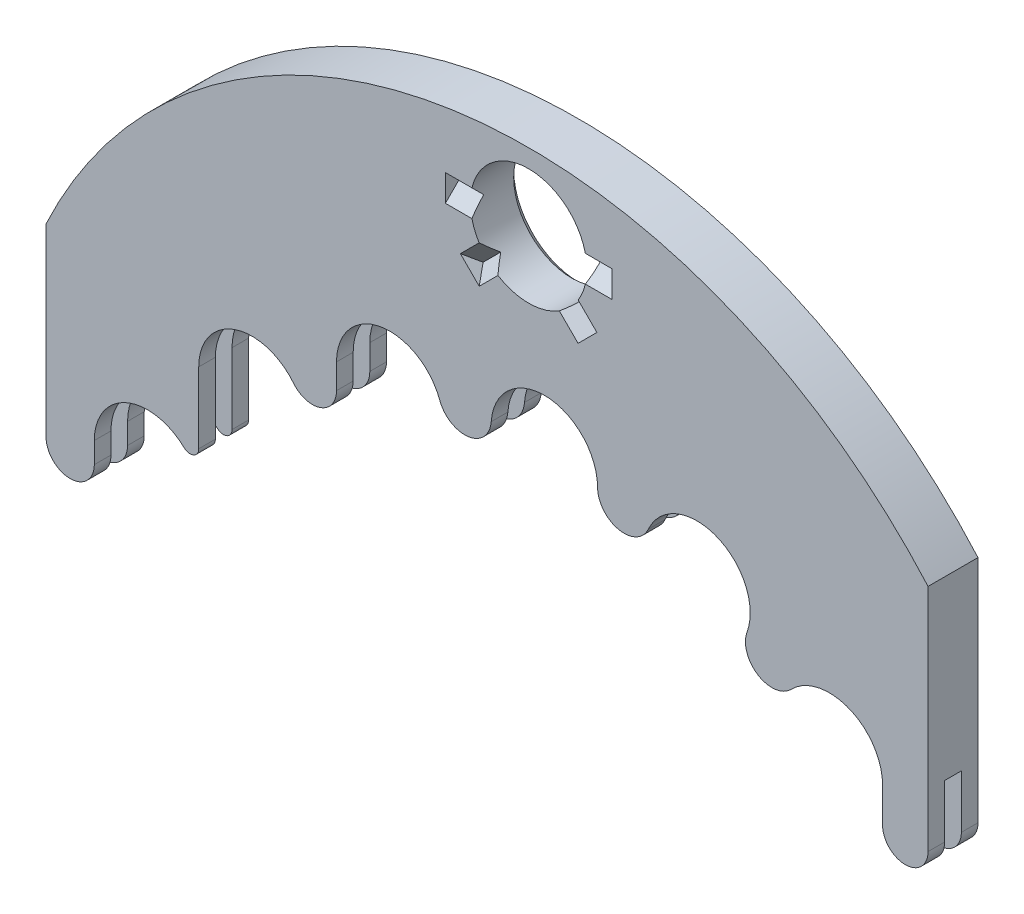
from build123d import *

# Parameters (mm, degrees)
SKETCH1_W               = 26.5
SKETCH1_H               = 15.5
BOSS_EXTRUDE1_DEPTH     = 0.75
CUT_EXTRUDE1_START      = -1.5
CUT_EXTRUDE1_DEPTH      = 1.5
SKETCH3_R               = 16
CUT_EXTRUDE2_DEPTH      = 0.25
SKETCH5_R               = 13
CUT_EXTRUDE3_DEPTH      = 2.5
CUT_EXTRUDE9_DEPTH      = 2.5
SKETCH8_R               = 1.75
CUT_EXTRUDE6_DEPTH      = 2.5
SKETCH4_R               = 1.6
CUT_EXTRUDE7_DEPTH      = 1.75
CUT_EXTRUDE7_DEPTH_BACK = 1.75
CUT_EXTRUDE8_DEPTH      = 2.5
CUT_EXTRUDE10_DEPTH     = 2.5
CUT_EXTRUDE11_DEPTH     = 2.5
CHAMFER1_SIZE           = 0.2
CUT_EXTRUDE12_DEPTH     = 2.5
CIRPATTERN1_COUNT       = 2
CIRPATTERN1_ANGLE       = 45
MIRROR1_COPY_1_DEPTH    = 2.5


with BuildPart() as part:
    # Sketch1 → Boss-Extrude1 (new body, symmetric)
    with BuildSketch(Plane.XY):
        Rectangle(SKETCH1_W, SKETCH1_H)
    extrude(amount=BOSS_EXTRUDE1_DEPTH, both=True)

    # Sketch2 → Cut-Extrude1 (cut)
    with BuildSketch(Plane.XY.offset(0.75).offset(CUT_EXTRUDE1_START)):
        with BuildLine():
            Line((-13.25, 9.75), (-13.25, -1.486125371))
            ThreePointArc((-13.25, -1.486125371), (-1.032310159, 7.586384068), (13.25, 2.333005244))
            Line((13.25, 2.333005244), (13.25, 9.75))
            Line((13.25, 9.75), (-13.25, 9.75))
        make_face()
    extrude(amount=CUT_EXTRUDE1_DEPTH, mode=Mode.SUBTRACT)

    # Sketch3 → Cut-Extrude2 (cut, symmetric)
    with BuildSketch(Plane.XY):
        with Locations((1.25, -13.55)):
            Circle(SKETCH3_R)
    extrude(amount=CUT_EXTRUDE2_DEPTH, both=True, mode=Mode.SUBTRACT)

    # Sketch5 → Cut-Extrude3 (cut, through all)
    with BuildSketch(Plane.XY.offset(0.75)):
        with Locations((1.25, -13.55)):
            Circle(SKETCH5_R)
    extrude(amount=-CUT_EXTRUDE3_DEPTH, mode=Mode.SUBTRACT)

    # Sketch11 → Cut-Extrude9 (cut, through all)
    with BuildSketch(Plane.XY.offset(0.75)):
        with BuildLine():
            Line((11.255498488, -5.25), (13.25, -5.25))
            Line((13.25, -5.25), (13.25, -7.75))
            Line((13.25, -7.75), (12.884431658, -7.75))
            ThreePointArc((12.884431658, -7.75), (12.141930232, -6.453109426), (11.255498488, -5.25))
        make_face()
    extrude(amount=-CUT_EXTRUDE9_DEPTH, mode=Mode.SUBTRACT)

    # Sketch8 → Cut-Extrude6 (cut, through all)
    with BuildSketch(Plane.XY.offset(0.75)):
        with Locations((1.25, 5.45)):
            Circle(SKETCH8_R)
    extrude(amount=-CUT_EXTRUDE6_DEPTH, mode=Mode.SUBTRACT)

    # Sketch4 → Cut-Extrude7 (cut, two sides)
    with BuildSketch(Plane.XY) as cut_extrude7_sk:
        with Locations((1.721143205, -0.058223835)):
            Circle(SKETCH4_R)
        with Locations((6.307189011, -1.033017963)):
            Circle(SKETCH4_R)
        with Locations((10.283263186, -3.517544856)):
            Circle(SKETCH4_R)
        with Locations((-2.921729424, -0.71073703)):
            Circle(SKETCH4_R)
        with Locations((-7.061429917, -2.911854826)):
            Circle(SKETCH4_R)
        with Locations((-10.198649298, -6.396089933)):
            Circle(SKETCH4_R)
    extrude(amount=CUT_EXTRUDE7_DEPTH, mode=Mode.SUBTRACT)
    extrude(cut_extrude7_sk.sketch, amount=-CUT_EXTRUDE7_DEPTH_BACK, mode=Mode.SUBTRACT)

    # Sketch9 → Cut-Extrude8 (cut, through all)
    with BuildSketch(Plane.XY.offset(0.75)):
        with BuildLine():
            Line((-11.798649298, -6.396089933), (-11.798649298, -7.024324649))
            ThreePointArc((-11.798649298, -7.024324649), (-12.524324649, -7.75), (-13.25, -7.024324649))
            Line((-13.25, -7.024324649), (-13.25, -8.25))
            Line((-13.25, -8.25), (-11.05124975, -8.25))
            Line((-11.05124975, -8.25), (-11.05124975, -7.75))
            ThreePointArc((-11.05124975, -7.75), (-11.599392087, -7.169342569), (-11.798649298, -6.396089933))
        make_face()
    extrude(amount=-CUT_EXTRUDE8_DEPTH, mode=Mode.SUBTRACT)

    # Sketch12 → Cut-Extrude10 (cut, through all)
    with BuildSketch(Plane.XY.offset(0.75)):
        with BuildLine():
            Line((11.883263186, -3.517544856), (11.883263186, -4.566631593))
            ThreePointArc((11.883263186, -4.566631593), (12.566631593, -5.25), (13.25, -4.566631593))
            Line((13.25, -4.566631593), (13.25, -5.75))
            Line((13.25, -5.75), (11.255498488, -5.75))
            Line((11.255498488, -5.75), (11.255498488, -5.25))
            ThreePointArc((11.255498488, -5.25), (11.12789237, -5.098536084), (10.997993608, -4.949033739))
            ThreePointArc((10.997993608, -4.949033739), (11.644066014, -4.359100358), (11.883263186, -3.517544856))
        make_face()
    extrude(amount=-CUT_EXTRUDE10_DEPTH, mode=Mode.SUBTRACT)

    # Sketch13 → Cut-Extrude11 (cut, through all)
    with BuildSketch(Plane.XY.offset(0.75)):
        with BuildLine():
            Line((-8.661429917, -2.911854826), (-8.661429917, -5.042786286))
            ThreePointArc((-8.661429917, -5.042786286), (-8.818746964, -5.281977988), (-9.100687262, -5.232268912))
            ThreePointArc((-9.100687262, -5.232268912), (-8.836495341, -5.556723149), (-8.665455555, -5.938578244))
            ThreePointArc((-8.665455555, -5.938578244), (1.881828141, -1.065978484), (11.883263186, -6.978568343))
            Line((11.883263186, -6.978568343), (11.883263186, -3.517544856))
            ThreePointArc((11.883263186, -3.517544856), (10.883946092, -2.034581591), (9.134288128, -2.404056501))
            ThreePointArc((9.134288128, -2.404056501), (8.138950435, -2.52537475), (7.811663229, -1.577588737))
            ThreePointArc((7.811663229, -1.577588737), (6.906559561, 0.450476204), (4.846670181, -0.379653786))
            ThreePointArc((4.846670181, -0.379653786), (3.952851981, -0.83408119), (3.3211407, -0.055392485))
            ThreePointArc((3.3211407, -0.055392485), (1.7769824, 1.540801488), (0.125240729, 0.056210801))
            ThreePointArc((0.125240729, 0.056210801), (-0.559250312, -0.676515106), (-1.419191964, -0.160845059))
            ThreePointArc((-1.419191964, -0.160845059), (-3.200960568, 0.864708929), (-4.521729424, -0.71073703))
            Line((-4.521729424, -0.71073703), (-4.521729424, -1.460419063))
            ThreePointArc((-4.521729424, -1.460419063), (-5.006380866, -2.143921837), (-5.811741986, -1.912715158))
            ThreePointArc((-5.811741986, -1.912715158), (-7.590816029, -1.401970611), (-8.661429917, -2.911854826))
        make_face()
    extrude(amount=-CUT_EXTRUDE11_DEPTH, mode=Mode.SUBTRACT)

    # Chamfer1
    chamfer1_edges = [part.edges().sort_by_distance(p)[0] for p in [
        (-0.5, 5.45, -0.75),
    ]]
    chamfer(chamfer1_edges, length=CHAMFER1_SIZE)

    # Sketch14 → Cut-Extrude12 (cut)
    with BuildSketch(Plane.ZY.offset(-1.25)):
        Polygon((0.75, 5.85), (0.35, 5.45), (0.75, 5.05), align=None)
    cut_extrude12 = extrude(amount=CUT_EXTRUDE12_DEPTH, mode=Mode.SUBTRACT)

    # CirPattern1: Cut-Extrude12 ×2 about axis
    cirpattern1_axis = Axis((1.25, 5.45, 0), (0, 0, 1))
    for i in range(1, CIRPATTERN1_COUNT):
        add(cut_extrude12.rotate(cirpattern1_axis, i * CIRPATTERN1_ANGLE / (CIRPATTERN1_COUNT - 1)), mode=Mode.SUBTRACT)

    # Mirror1: Cut-Extrude12 across plane
    add(cut_extrude12.mirror(Plane.ZY.offset(-1.25)), mode=Mode.SUBTRACT)

    # Mirror1 copy 1 sketch → Mirror1 copy 1 (cut)
    with BuildSketch(Plane(origin=(-2.603731957, 1.596268043, 0), x_dir=(0, 0, 1), z_dir=(0.707106781, -0.707106781, 0))):
        Polygon((0.75, -5.85), (0.35, -5.45), (0.75, -5.05), align=None)
    extrude(amount=MIRROR1_COPY_1_DEPTH, mode=Mode.SUBTRACT)


solid = part.part
